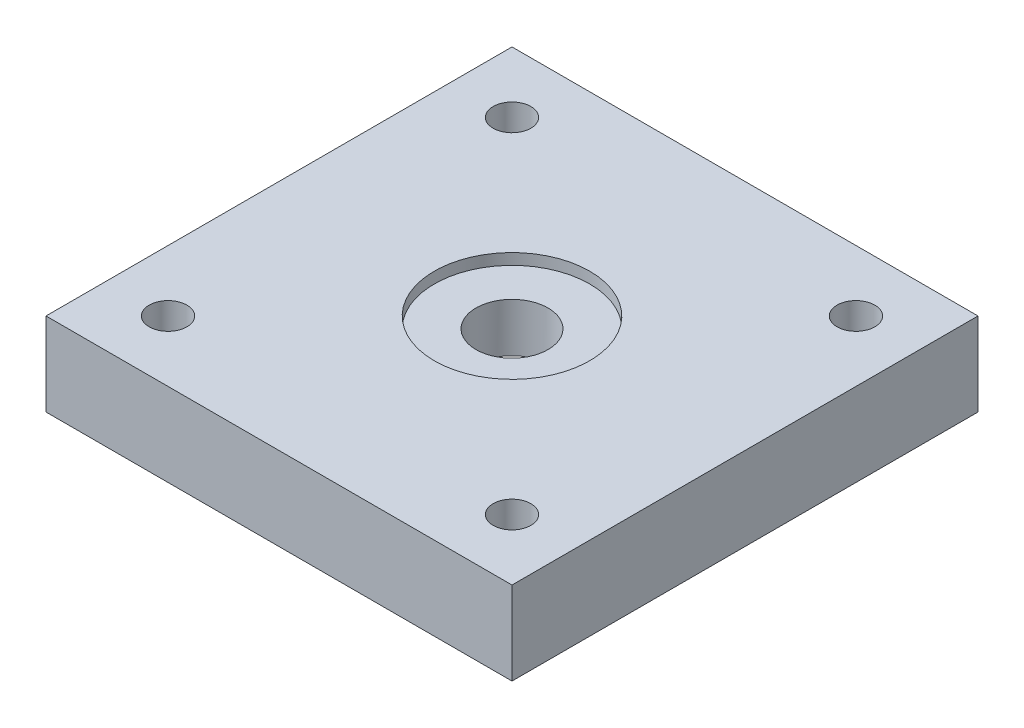
from build123d import *

# Parameters (mm, degrees)
SKETCH1_W           = 42
SKETCH1_H           = 42
SKETCH1_R           = 1.7
BOSS_EXTRUDE1_DEPTH = 7.5
SKETCH2_R           = 11
CUT_EXTRUDE1_DEPTH  = 2.1
SKETCH3_R           = 7
CUT_EXTRUDE2_DEPTH  = 1
SKETCH4_R           = 3.25
CUT_EXTRUDE3_DEPTH  = 10


with BuildPart() as part:
    # Sketch1 → Boss-Extrude1 (new body)
    with BuildSketch(Plane(origin=(0, 0, 0), x_dir=(1, 0, 0), z_dir=(0, 1, 0))):
        Rectangle(SKETCH1_W, SKETCH1_H)
        with Locations((-15.5, 15.5)):
            Circle(SKETCH1_R, mode=Mode.SUBTRACT)
        with Locations((15.5, 15.5)):
            Circle(SKETCH1_R, mode=Mode.SUBTRACT)
        with Locations((15.5, -15.5)):
            Circle(SKETCH1_R, mode=Mode.SUBTRACT)
        with Locations((-15.5, -15.5)):
            Circle(SKETCH1_R, mode=Mode.SUBTRACT)
    extrude(amount=BOSS_EXTRUDE1_DEPTH)

    # Sketch2 → Cut-Extrude1 (cut)
    with BuildSketch(Plane(origin=(0, 0, 0), x_dir=(-1, 0, 0), z_dir=(0, -1, 0))):
        Circle(SKETCH2_R)
    extrude(amount=-CUT_EXTRUDE1_DEPTH, mode=Mode.SUBTRACT)

    # Sketch3 → Cut-Extrude2 (cut)
    with BuildSketch(Plane(origin=(0, 7.5, 0), x_dir=(1, 0, 0), z_dir=(0, 1, 0))):
        Circle(SKETCH3_R)
    extrude(amount=-CUT_EXTRUDE2_DEPTH, mode=Mode.SUBTRACT)

    # Sketch4 → Cut-Extrude3 (cut)
    with BuildSketch(Plane(origin=(0, 6.5, 0), x_dir=(1, 0, 0), z_dir=(0, 1, 0))):
        Circle(SKETCH4_R)
    extrude(amount=-CUT_EXTRUDE3_DEPTH, mode=Mode.SUBTRACT)


solid = part.part
